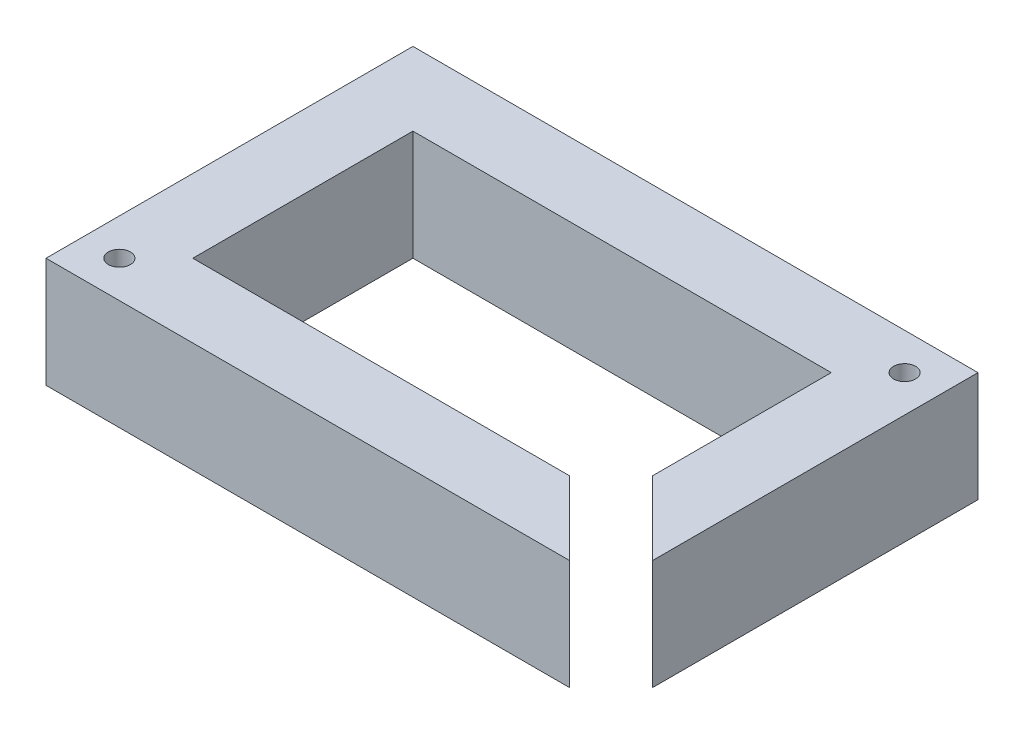
from build123d import *

# Parameters (mm, degrees)
SKETCH1_R           = 1.5
BOSS_EXTRUDE1_DEPTH = 15


with BuildPart() as part:
    # Sketch1 → Boss-Extrude1 (new body)
    with BuildSketch(Plane(origin=(0, 0, 0), x_dir=(1, 0, 0), z_dir=(0, 1, 0))):
        Polygon((67, 40), (-10, 40), (-10, -10), (61.343145751, -10), (51.343145751, 0), (0, 0), (0, 30), (57, 30), (57, 5.656854249), (67, -4.343145751), align=None)
        with Locations((-5, -5)):
            Circle(SKETCH1_R, mode=Mode.SUBTRACT)
        with Locations((62, 35)):
            Circle(SKETCH1_R, mode=Mode.SUBTRACT)
    extrude(amount=BOSS_EXTRUDE1_DEPTH)


solid = part.part
